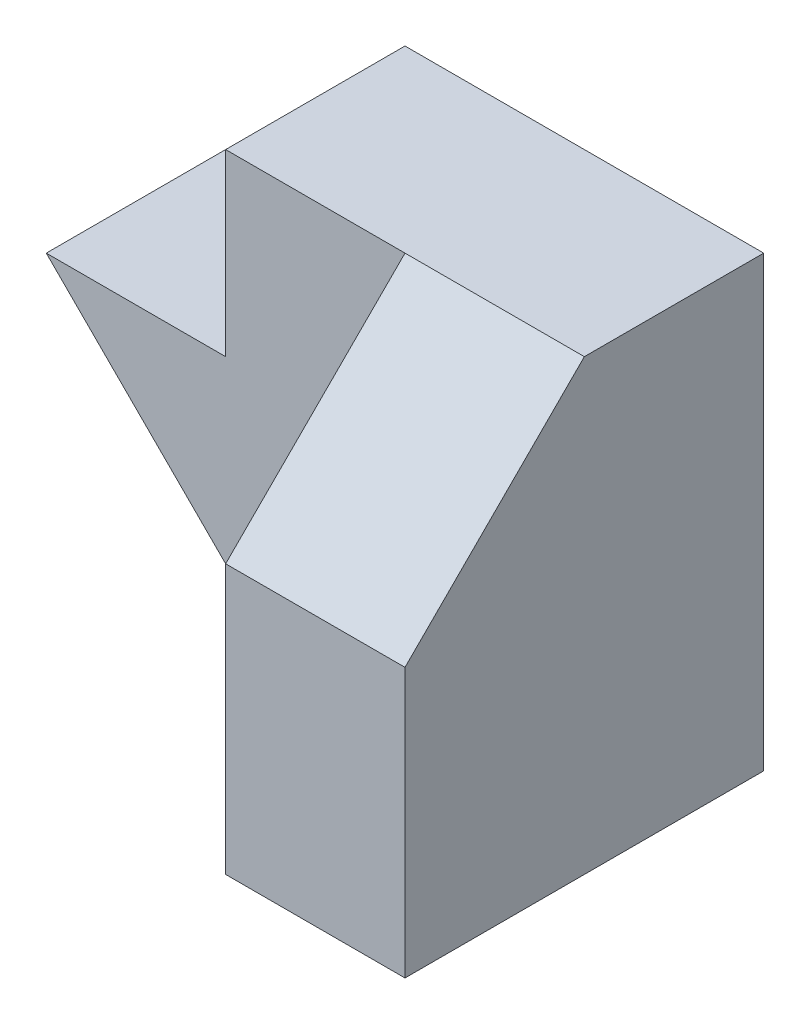
from build123d import *

# Parameters (mm, degrees)
BOSS_EXTRUDE1_DEPTH = 20
CUT_EXTRUDE1_DEPTH  = 10
CUT_EXTRUDE2_DEPTH  = 10


with BuildPart() as part:
    # Sketch1 → Boss-Extrude1 (new body)
    with BuildSketch(Plane.XY):
        Polygon((0, 0), (15, 0), (15, 25), (-5, 25), (-5, 15), (-15, 15), align=None)
    extrude(amount=BOSS_EXTRUDE1_DEPTH)

    # Sketch2 → Cut-Extrude1 (cut)
    with BuildSketch(Plane.XY.offset(20)):
        Polygon((5, 25), (5, 0), (0, 0), (-15, 15), (-5, 15), (-5, 25), align=None)
    extrude(amount=-CUT_EXTRUDE1_DEPTH, mode=Mode.SUBTRACT)

    # Sketch3 → Cut-Extrude2 (cut)
    with BuildSketch(Plane.ZY.offset(-5)):
        Polygon((10, 25), (20, 25), (20, 15), align=None)
    extrude(amount=-CUT_EXTRUDE2_DEPTH, mode=Mode.SUBTRACT)


solid = part.part
